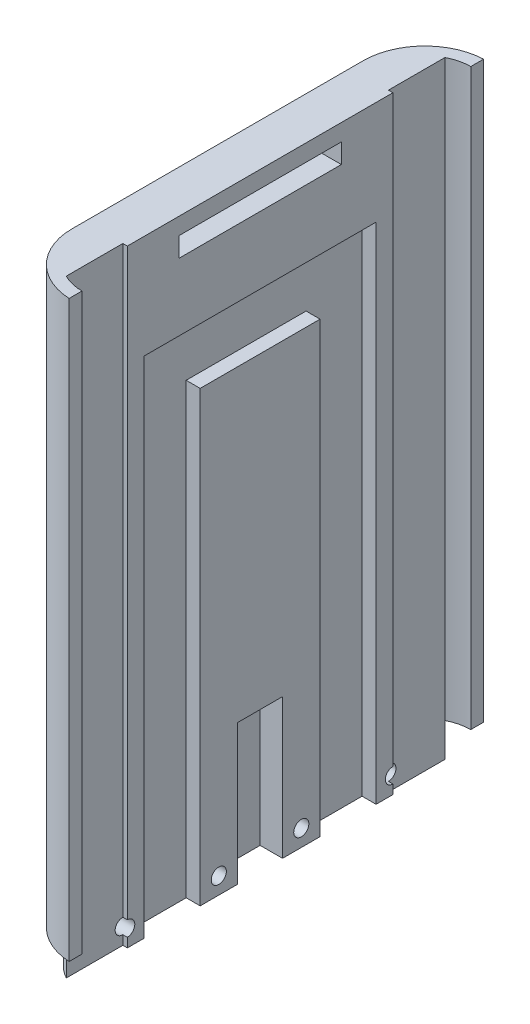
from build123d import *

# Parameters (mm, degrees)
BOSS_EXTRUDE1_DEPTH = 120
BOSS_EXTRUDE2_DEPTH = 120
SKETCH4_W           = 0.8
SKETCH4_H           = 47.4
BOSS_EXTRUDE3_DEPTH = 120
BOSS_EXTRUDE4_DEPTH = 6
SKETCH6_W           = 3.197214061
SKETCH6_H           = 10
SKETCH6_W_2         = 2.544721395
CUT_EXTRUDE1_DEPTH  = 90
SKETCH7_W           = 91.376615624
SKETCH7_H           = 120.194280457
CUT_EXTRUDE3_DEPTH  = 258
SKETCH8_W           = 8
SKETCH8_H           = 30.385133663
CUT_EXTRUDE4_DEPTH  = 4
SKETCH9_R           = 1.35
CUT_EXTRUDE5_DEPTH  = 11
SKETCH10_W          = 29
SKETCH10_H          = 3.5
CUT_EXTRUDE6_DEPTH  = 10
SKETCH11_W          = 115.146040633
SKETCH11_H          = 26.021704098
CUT_EXTRUDE7_DEPTH  = 103
SKETCH12_W          = 27.624810525
SKETCH12_H          = 10
CUT_EXTRUDE8_DEPTH  = 2.5
SKETCH13_R          = 1.35
CUT_EXTRUDE9_DEPTH  = 5


with BuildPart() as part:
    # Sketch1 → Boss-Extrude1 (new body)
    with BuildSketch(Plane(origin=(0, 0, 0), x_dir=(1, 0, 0), z_dir=(0, 1, 0))):
        with BuildLine():
            Line((-55.813088795, 29.403372847), (-55.813088795, -22.596627153))
            ThreePointArc((-55.813088795, -22.596627153), (-52.766075655, -30.195969229), (-45.313088795, -33.585257641))
            Line((-45.313088795, -33.585257641), (-45.313088795, -31.296627153))
            ThreePointArc((-45.313088795, -31.296627153), (-50.969943044, -28.953481402), (-53.313088795, -23.296627153))
            Line((-53.313088795, -23.296627153), (-53.313088795, 30.103372847))
            ThreePointArc((-53.313088795, 30.103372847), (-50.969943044, 35.760227097), (-45.313088795, 38.103372847))
            Line((-45.313088795, 38.103372847), (-45.313088795, 40.392003335))
            ThreePointArc((-45.313088795, 40.392003335), (-52.766075655, 37.002714924), (-55.813088795, 29.403372847))
        make_face()
        with BuildLine():
            Line((-45.313088795, -31.296627153), (-45.313088795, -33.585257641))
            ThreePointArc((-45.313088795, -33.585257641), (-45.063153419, -33.593784407), (-44.813088795, -33.596627153))
            Line((-44.813088795, -33.596627153), (7.186911205, -33.596627153))
            ThreePointArc((7.186911205, -33.596627153), (14.965085798, -30.374801746), (18.186911205, -22.596627153))
            Line((18.186911205, -22.596627153), (18.186911205, 29.403372847))
            ThreePointArc((18.186911205, 29.403372847), (14.965085798, 37.18154744), (7.186911205, 40.403372847))
            Line((7.186911205, 40.403372847), (-45.313088795, 40.403372847))
            Line((-45.313088795, 40.403372847), (-45.313088795, 40.392003335))
            Line((-45.313088795, 40.392003335), (-45.313088795, 38.103372847))
            Line((-45.313088795, 38.103372847), (7.686911205, 38.103372847))
            ThreePointArc((7.686911205, 38.103372847), (13.343765455, 35.760227097), (15.686911205, 30.103372847))
            Line((15.686911205, 30.103372847), (15.686911205, -23.296627153))
            ThreePointArc((15.686911205, -23.296627153), (13.343765455, -28.953481402), (7.686911205, -31.296627153))
            Line((7.686911205, -31.296627153), (-45.313088795, -31.296627153))
        make_face()
    extrude(amount=BOSS_EXTRUDE1_DEPTH)

    # Sketch3 → Boss-Extrude2 (add)
    with BuildSketch(Plane.XZ):
        Polygon((-49.013088795, 31.972735522), (-49.013088795, -37.623215713), (-53.336517426, -34.913867104), (-55.11106611, -29.984565206), (-55.11106611, -26.811210851), (-55.11106611, 25.452378342), (-53.652842224, 27.779331351), (-52.073193111, 30.226675048), align=None)
        Polygon((11.386911205, 31.972735522), (11.386911205, -38.487790626), (13.269736219, -37.809973621), (16.737085445, -32.276969537), (16.568342629, -31.170966754), (16.568342629, 24.789777041), (15.03852436, 28.997230807), align=None)
    extrude(amount=-BOSS_EXTRUDE2_DEPTH)

    # Sketch4 → Boss-Extrude3 (add)
    with BuildSketch(Plane.XZ):
        with Locations((10.986911205, -3.403372847)):
            Rectangle(SKETCH4_W, SKETCH4_H)
        with Locations((-48.613088795, -3.403372847)):
            Rectangle(SKETCH4_W, SKETCH4_H)
    extrude(amount=-BOSS_EXTRUDE3_DEPTH)

    # Sketch5 → Boss-Extrude4 (add)
    with BuildSketch(Plane.XZ):
        with BuildLine():
            ThreePointArc((-49.013088795, 30.389581403), (-52.154141346, 27.443915423), (-53.313088795, 23.296627153))
            Line((-53.313088795, 23.296627153), (-53.313088795, -30.103372847))
            ThreePointArc((-53.313088795, -30.103372847), (-52.154141346, -34.250661118), (-49.013088795, -37.196327098))
            Line((-49.013088795, -37.196327098), (-49.013088795, -27.103372847))
            Line((-49.013088795, -27.103372847), (-48.213088795, -27.103372847))
            Line((-48.213088795, -27.103372847), (-48.213088795, 20.296627153))
            Line((-48.213088795, 20.296627153), (-49.013088795, 20.296627153))
            Line((-49.013088795, 20.296627153), (-49.013088795, 30.389581403))
        make_face()
        with BuildLine():
            ThreePointArc((11.386911205, -37.196327098), (14.527963756, -34.250661118), (15.686911205, -30.103372847))
            Line((15.686911205, -30.103372847), (15.686911205, 23.296627153))
            ThreePointArc((15.686911205, 23.296627153), (14.527963756, 27.443915423), (11.386911205, 30.389581403))
            Line((11.386911205, 30.389581403), (11.386911205, 20.296627153))
            Line((11.386911205, 20.296627153), (10.586911205, 20.296627153))
            Line((10.586911205, 20.296627153), (10.586911205, -27.103372847))
            Line((10.586911205, -27.103372847), (11.386911205, -27.103372847))
            Line((11.386911205, -27.103372847), (11.386911205, -37.196327098))
        make_face()
    extrude(amount=BOSS_EXTRUDE4_DEPTH)

    # Sketch6 → Cut-Extrude1 (cut)
    with BuildSketch(Plane.XZ.offset(6)):
        with Locations((-49.114481764, 12.296627153)):
            Rectangle(SKETCH6_W, SKETCH6_H)
        with Locations((-49.440728097, -19.103372847)):
            Rectangle(SKETCH6_W_2, SKETCH6_H)
        with Locations((11.814550508, -19.103372847)):
            Rectangle(SKETCH6_W_2, SKETCH6_H)
        with Locations((11.488304175, 12.296627153)):
            Rectangle(SKETCH6_W, SKETCH6_H)
    extrude(amount=-CUT_EXTRUDE1_DEPTH, mode=Mode.SUBTRACT)

    # Sketch7 → Cut-Extrude3 (cut)
    with BuildSketch(Plane.XZ.offset(6)):
        with Locations((0.375219017, -9.755963426)):
            Rectangle(SKETCH7_W, SKETCH7_H)
    extrude(amount=-CUT_EXTRUDE3_DEPTH, mode=Mode.SUBTRACT)

    # Sketch8 → Cut-Extrude4 (cut)
    with BuildSketch(Plane(origin=(-48.213088795, 0, 0), x_dir=(0, 0, -1), z_dir=(1, 0, 0))):
        with Locations((3.403372847, 3.807433168)):
            Rectangle(SKETCH8_W, SKETCH8_H)
    extrude(amount=-CUT_EXTRUDE4_DEPTH, mode=Mode.SUBTRACT)

    # Sketch9 → Cut-Extrude5 (cut)
    with BuildSketch(Plane(origin=(-48.213088795, 0, 0), x_dir=(0, 0, -1), z_dir=(1, 0, 0))):
        with Locations((-3.969366177, -3)):
            Circle(SKETCH9_R)
        with Locations((10.753372847, -3)):
            Circle(SKETCH9_R)
        with Locations((-20.319366177, -3)):
            Circle(SKETCH9_R)
        with Locations((27.103372847, -3)):
            Circle(SKETCH9_R)
    extrude(amount=-CUT_EXTRUDE5_DEPTH, mode=Mode.SUBTRACT)

    # Sketch10 → Cut-Extrude6 (cut)
    with BuildSketch(Plane.ZY.offset(55.813088795)):
        with Locations((-3.403372847, 97.75)):
            Rectangle(SKETCH10_W, SKETCH10_H)
    extrude(amount=-CUT_EXTRUDE6_DEPTH, mode=Mode.SUBTRACT)

    # Sketch11 → Cut-Extrude7 (cut)
    with BuildSketch(Plane.ZY.offset(55.813088795)):
        with Locations((0.013322813, 115.510852049)):
            Rectangle(SKETCH11_W, SKETCH11_H)
    extrude(amount=-CUT_EXTRUDE7_DEPTH, mode=Mode.SUBTRACT)

    # Sketch12 → Cut-Extrude8 (cut)
    with BuildSketch(Plane(origin=(-48.213088795, 0, 0), x_dir=(0, 0, -1), z_dir=(1, 0, 0))):
        with Locations((4.217176257, 79)):
            Rectangle(SKETCH12_W, SKETCH12_H)
    extrude(amount=-CUT_EXTRUDE8_DEPTH, mode=Mode.SUBTRACT)

    # Sketch13 → Cut-Extrude9 (cut)
    with BuildSketch(Plane.ZY.offset(55.813088795)):
        with Locations((-23.403372847, 98.5)):
            Circle(SKETCH13_R)
        with Locations((16.596627153, 98.5)):
            Circle(SKETCH13_R)
    extrude(amount=-CUT_EXTRUDE9_DEPTH, mode=Mode.SUBTRACT)


solid = part.part
